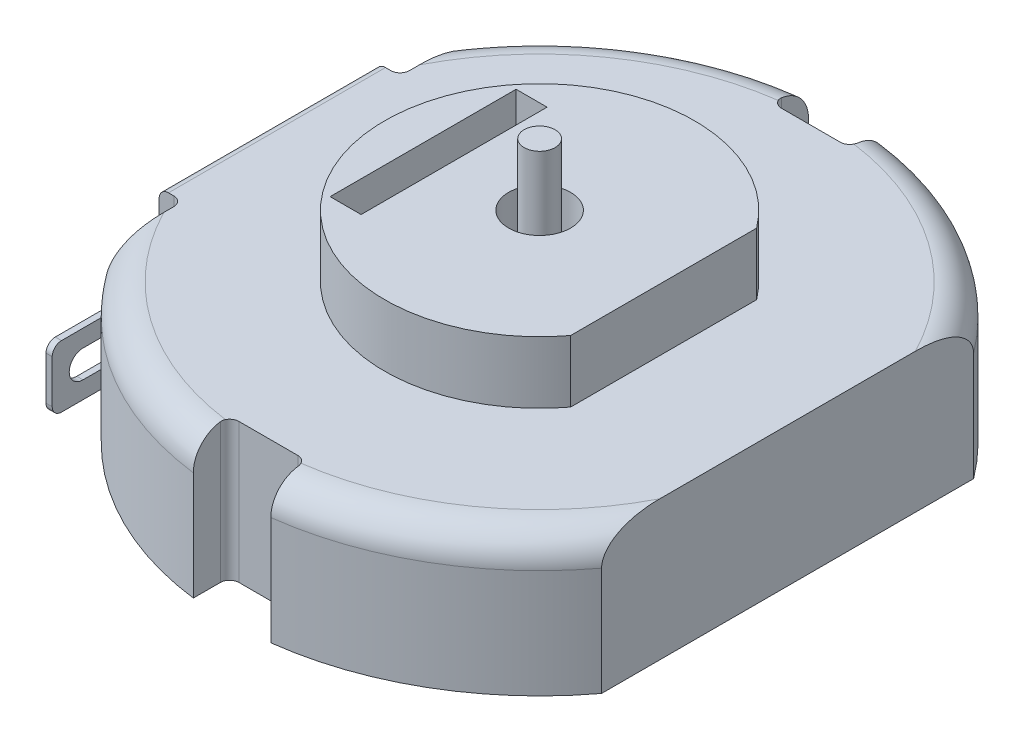
from build123d import *

# Parameters (mm, degrees)
BOSS_EXTRUDE1_DEPTH  = 4.5
SKETCH2_W            = 1
SKETCH2_H            = 6
BOSS_EXTRUDE2_DEPTH  = 2
SKETCH3_R            = 1
SKETCH3_R_2          = 0.5
CUT_EXTRUDE1_DEPTH   = 2
SKETCH3_2_R          = 0.5
BOSS_EXTRUDE3_DEPTH  = 2
FILLET1_R            = 1
SKETCH4_W            = 2.5
SKETCH4_H            = 2.5
CUT_EXTRUDE2_DEPTH   = 5.5000001
FILLET2_R            = 0.3
BOSS_EXTRUDE4_DEPTH  = 3.5
FILLET3_R            = 0.3
SKETCH7_W            = 0.772874032
SKETCH7_H            = 2.696512764
BOSS_EXTRUDE5_DEPTH  = 3.5
SKETCH8_W            = 0.2
SKETCH8_H            = 2
BOSS_EXTRUDE6_DEPTH  = 4
FILLET4_R            = 0.3
CUT_EXTRUDE3_DEPTH   = 0.2
FILLET4_OF_MIRROR2_R = 0.3


with BuildPart() as part:
    # Sketch1 → Boss-Extrude1 (new body)
    with BuildSketch(Plane(origin=(0, 0, 0), x_dir=(1, 0, 0), z_dir=(0, 1, 0))):
        with BuildLine():
            Line((8, -6), (8, 6))
            ThreePointArc((8, 6), (0, 10), (-8, 6))
            Line((-8, 6), (-8, -6))
            ThreePointArc((-8, -6), (0, -10), (8, -6))
        make_face()
    extrude(amount=BOSS_EXTRUDE1_DEPTH)

    # Sketch2 → Boss-Extrude2 (add)
    with BuildSketch(Plane(origin=(0, 4.5, 0), x_dir=(1, 0, 0), z_dir=(0, 1, 0))):
        with BuildLine():
            Line((4, 3), (4, -3))
            ThreePointArc((4, -3), (-5, 0), (4, 3))
        make_face()
        with Locations((-3.258806918, 0)):
            Rectangle(SKETCH2_W, SKETCH2_H, mode=Mode.SUBTRACT)
    extrude(amount=BOSS_EXTRUDE2_DEPTH)

    # Sketch3 → Cut-Extrude1 (cut)
    with BuildSketch(Plane(origin=(0, 6.5, 0), x_dir=(1, 0, 0), z_dir=(0, 1, 0))):
        Circle(SKETCH3_R)
        Circle(SKETCH3_R_2, mode=Mode.SUBTRACT)
    extrude(amount=-CUT_EXTRUDE1_DEPTH, mode=Mode.SUBTRACT)

    # Sketch3_2 → Boss-Extrude3 (add)
    with BuildSketch(Plane(origin=(0, 6.5, 0), x_dir=(1, 0, 0), z_dir=(0, 1, 0))):
        Circle(SKETCH3_2_R)
    extrude(amount=BOSS_EXTRUDE3_DEPTH)

    # Fillet1
    fillet1_edges = [part.edges().sort_by_distance(p)[0] for p in [
        (0, 4.5, 10),
        (0, 4.5, -10),
    ]]
    fillet(fillet1_edges, radius=FILLET1_R)

    # Sketch4 → Cut-Extrude2 (cut, through all)
    with BuildSketch(Plane(origin=(0, 4.5, 0), x_dir=(1, 0, 0), z_dir=(0, 1, 0))):
        with Locations((0, -10)):
            Rectangle(SKETCH4_W, SKETCH4_H)
    cut_extrude2 = extrude(amount=-CUT_EXTRUDE2_DEPTH, mode=Mode.SUBTRACT)

    # Mirror1: Cut-Extrude2 across plane
    add(cut_extrude2.mirror(Plane.XY), mode=Mode.SUBTRACT)

    # Fillet2
    fillet2_edges = [part.edges().sort_by_distance(p)[0] for p in [
        (-1.25, 2.25, -8.75),
        (1.25, 2.25, -8.75),
        (1.25, 2.25, 8.75),
        (-1.25, 2.25, 8.75),
    ]]
    fillet(fillet2_edges, radius=FILLET2_R)

    # Sketch6 → Boss-Extrude4 (add, symmetric)
    with BuildSketch(Plane.XY):
        with BuildLine():
            Line((-8, 4.5), (-8.472874032, 4.5))
            ThreePointArc((-8.472874032, 4.5), (-8.685006066, 4.412132034), (-8.772874032, 4.2))
            Line((-8.772874032, 4.2), (-8.772874032, 3.028910777))
            Line((-8.772874032, 3.028910777), (-8, 3.028910777))
            Line((-8, 3.028910777), (-8, 4.5))
        make_face()
    extrude(amount=BOSS_EXTRUDE4_DEPTH, both=True)

    # Fillet3
    fillet3_edges = [part.edges().sort_by_distance(p)[0] for p in [
        (-8, 3.764455388, -3.5),
        (-8, 3.764455388, 3.5),
    ]]
    fillet(fillet3_edges, radius=FILLET3_R)

    # Sketch7 → Boss-Extrude5 (add, symmetric)
    with BuildSketch(Plane.XY):
        with Locations((-8.386437016, 1.348256382)):
            Rectangle(SKETCH7_W, SKETCH7_H)
    extrude(amount=BOSS_EXTRUDE5_DEPTH, both=True)

    # Sketch8 → Boss-Extrude6 (add)
    with BuildSketch(Plane(origin=(0, 0, -3.5), x_dir=(-1, 0, 0), z_dir=(0, 0, -1))):
        with Locations((8.323724086, 1.346512764)):
            Rectangle(SKETCH8_W, SKETCH8_H)
    boss_extrude6 = extrude(amount=BOSS_EXTRUDE6_DEPTH)

    # Fillet4
    fillet4_edges = [part.edges().sort_by_distance(p)[0] for p in [
        (-8.323724086, 0.346512764, -7.5),
        (-8.323724086, 2.346512764, -7.5),
    ]]
    fillet(fillet4_edges, radius=FILLET4_R)

    # Sketch9 → Cut-Extrude3 (cut)
    with BuildSketch(Plane.ZY.offset(8.423724086)):
        with BuildLine():
            Line((-6.506992038, 1.790165147), (-5.08730441, 1.790165147))
            ThreePointArc((-5.08730441, 1.790165147), (-4.643652026, 1.346512764), (-5.08730441, 0.90286038))
            Line((-5.08730441, 0.90286038), (-6.506992038, 0.90286038))
            ThreePointArc((-6.506992038, 0.90286038), (-6.950644422, 1.346512764), (-6.506992038, 1.790165147))
        make_face()
    cut_extrude3 = extrude(amount=-CUT_EXTRUDE3_DEPTH, mode=Mode.SUBTRACT)

    # Mirror2: Boss-Extrude6, Cut-Extrude3 across plane
    add(boss_extrude6.mirror(Plane.XY))
    add(cut_extrude3.mirror(Plane.XY), mode=Mode.SUBTRACT)

    # Fillet4 of Mirror2
    fillet4_of_mirror2_edges = [part.edges().sort_by_distance(p)[0] for p in [
        (-8.323724086, 0.346512764, 7.5),
        (-8.323724086, 2.346512764, 7.5),
    ]]
    fillet(fillet4_of_mirror2_edges, radius=FILLET4_OF_MIRROR2_R)


solid = part.part
